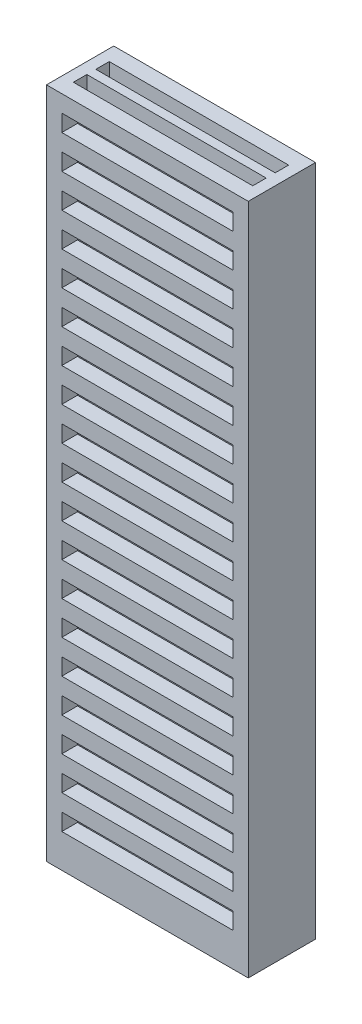
from build123d import *

# Parameters (mm, degrees)
SKETCH1_W                = 9
SKETCH1_H                = 3
BOSS_EXTRUDE1_DEPTH      = 15
CUT_EXTRUDE1_START       = -31
SKETCH2_W                = 8
SKETCH2_H                = 0.6
CUT_EXTRUDE1_DEPTH       = 32
SKETCH3_W                = 7.634272068
SKETCH3_H                = 0.75
CUT_EXTRUDE2_DEPTH       = 0.7
LPATTERN1_COUNT          = 19
LPATTERN1_PITCH          = 1.5
MIRROR2_COPY_1_SKETCH_W  = 7.634272068
MIRROR2_COPY_1_SKETCH_H  = 0.75
MIRROR2_COPY_1_DEPTH     = 0.7
MIRROR2_COPY_2_SKETCH_W  = 7.634272068
MIRROR2_COPY_2_SKETCH_H  = 0.75
MIRROR2_COPY_2_DEPTH     = 0.7
MIRROR2_COPY_3_SKETCH_W  = 7.634272068
MIRROR2_COPY_3_SKETCH_H  = 0.75
MIRROR2_COPY_3_DEPTH     = 0.7
MIRROR2_COPY_4_SKETCH_W  = 7.634272068
MIRROR2_COPY_4_SKETCH_H  = 0.75
MIRROR2_COPY_4_DEPTH     = 0.7
MIRROR2_COPY_5_SKETCH_W  = 7.634272068
MIRROR2_COPY_5_SKETCH_H  = 0.75
MIRROR2_COPY_5_DEPTH     = 0.7
MIRROR2_COPY_6_SKETCH_W  = 7.634272068
MIRROR2_COPY_6_SKETCH_H  = 0.75
MIRROR2_COPY_6_DEPTH     = 0.7
MIRROR2_COPY_7_SKETCH_W  = 7.634272068
MIRROR2_COPY_7_SKETCH_H  = 0.75
MIRROR2_COPY_7_DEPTH     = 0.7
MIRROR2_COPY_8_SKETCH_W  = 7.634272068
MIRROR2_COPY_8_SKETCH_H  = 0.75
MIRROR2_COPY_8_DEPTH     = 0.7
MIRROR2_COPY_9_SKETCH_W  = 7.634272068
MIRROR2_COPY_9_SKETCH_H  = 0.75
MIRROR2_COPY_9_DEPTH     = 0.7
MIRROR2_COPY_10_SKETCH_W = 7.634272068
MIRROR2_COPY_10_SKETCH_H = 0.75
MIRROR2_COPY_10_DEPTH    = 0.7
MIRROR2_COPY_11_SKETCH_W = 7.634272068
MIRROR2_COPY_11_SKETCH_H = 0.75
MIRROR2_COPY_11_DEPTH    = 0.7
MIRROR2_COPY_12_SKETCH_W = 7.634272068
MIRROR2_COPY_12_SKETCH_H = 0.75
MIRROR2_COPY_12_DEPTH    = 0.7
MIRROR2_COPY_13_SKETCH_W = 7.634272068
MIRROR2_COPY_13_SKETCH_H = 0.75
MIRROR2_COPY_13_DEPTH    = 0.7
MIRROR2_COPY_14_SKETCH_W = 7.634272068
MIRROR2_COPY_14_SKETCH_H = 0.75
MIRROR2_COPY_14_DEPTH    = 0.7
MIRROR2_COPY_15_SKETCH_W = 7.634272068
MIRROR2_COPY_15_SKETCH_H = 0.75
MIRROR2_COPY_15_DEPTH    = 0.7
MIRROR2_COPY_16_SKETCH_W = 7.634272068
MIRROR2_COPY_16_SKETCH_H = 0.75
MIRROR2_COPY_16_DEPTH    = 0.7
MIRROR2_COPY_17_SKETCH_W = 7.634272068
MIRROR2_COPY_17_SKETCH_H = 0.75
MIRROR2_COPY_17_DEPTH    = 0.7
MIRROR2_COPY_18_SKETCH_W = 7.634272068
MIRROR2_COPY_18_SKETCH_H = 0.75
MIRROR2_COPY_18_DEPTH    = 0.7


with BuildPart() as part:
    # Sketch1 → Boss-Extrude1 (new body, symmetric)
    with BuildSketch(Plane(origin=(0, 0, 0), x_dir=(1, 0, 0), z_dir=(0, 1, 0))):
        Rectangle(SKETCH1_W, SKETCH1_H)
    extrude(amount=BOSS_EXTRUDE1_DEPTH, both=True)

    # Sketch2 → Cut-Extrude1 (cut)
    with BuildSketch(Plane(origin=(0, 15, 0), x_dir=(1, 0, 0), z_dir=(0, 1, 0)).offset(CUT_EXTRUDE1_START)):
        with Locations((0, 0.5)):
            Rectangle(SKETCH2_W, SKETCH2_H)
    cut_extrude1 = extrude(amount=CUT_EXTRUDE1_DEPTH, mode=Mode.SUBTRACT)

    # Mirror1: Cut-Extrude1 across plane
    add(cut_extrude1.mirror(Plane.XY), mode=Mode.SUBTRACT)

    # Sketch3 → Cut-Extrude2 (cut)
    with BuildSketch(Plane.XY.offset(1.5)):
        with Locations((0, 13.875)):
            Rectangle(SKETCH3_W, SKETCH3_H)
    cut_extrude2 = extrude(amount=-CUT_EXTRUDE2_DEPTH, mode=Mode.SUBTRACT)

    # LPattern1: Cut-Extrude2 ×19
    with Locations(*[(0, -i * LPATTERN1_PITCH, 0) for i in range(1, LPATTERN1_COUNT)]):
        add(cut_extrude2, mode=Mode.SUBTRACT)

    # Mirror2: Cut-Extrude2 across plane
    add(cut_extrude2.mirror(Plane.XY), mode=Mode.SUBTRACT)

    # Mirror2 copy 1 sketch → Mirror2 copy 1 (cut)
    with BuildSketch(Plane(origin=(0, -1.5, -1.5), x_dir=(1, 0, 0), z_dir=(0, 0, -1))):
        with Locations((0, -13.875)):
            Rectangle(MIRROR2_COPY_1_SKETCH_W, MIRROR2_COPY_1_SKETCH_H)
    extrude(amount=-MIRROR2_COPY_1_DEPTH, mode=Mode.SUBTRACT)

    # Mirror2 copy 2 sketch → Mirror2 copy 2 (cut)
    with BuildSketch(Plane(origin=(0, -3, -1.5), x_dir=(1, 0, 0), z_dir=(0, 0, -1))):
        with Locations((0, -13.875)):
            Rectangle(MIRROR2_COPY_2_SKETCH_W, MIRROR2_COPY_2_SKETCH_H)
    extrude(amount=-MIRROR2_COPY_2_DEPTH, mode=Mode.SUBTRACT)

    # Mirror2 copy 3 sketch → Mirror2 copy 3 (cut)
    with BuildSketch(Plane(origin=(0, -4.5, -1.5), x_dir=(1, 0, 0), z_dir=(0, 0, -1))):
        with Locations((0, -13.875)):
            Rectangle(MIRROR2_COPY_3_SKETCH_W, MIRROR2_COPY_3_SKETCH_H)
    extrude(amount=-MIRROR2_COPY_3_DEPTH, mode=Mode.SUBTRACT)

    # Mirror2 copy 4 sketch → Mirror2 copy 4 (cut)
    with BuildSketch(Plane(origin=(0, -6, -1.5), x_dir=(1, 0, 0), z_dir=(0, 0, -1))):
        with Locations((0, -13.875)):
            Rectangle(MIRROR2_COPY_4_SKETCH_W, MIRROR2_COPY_4_SKETCH_H)
    extrude(amount=-MIRROR2_COPY_4_DEPTH, mode=Mode.SUBTRACT)

    # Mirror2 copy 5 sketch → Mirror2 copy 5 (cut)
    with BuildSketch(Plane(origin=(0, -7.5, -1.5), x_dir=(1, 0, 0), z_dir=(0, 0, -1))):
        with Locations((0, -13.875)):
            Rectangle(MIRROR2_COPY_5_SKETCH_W, MIRROR2_COPY_5_SKETCH_H)
    extrude(amount=-MIRROR2_COPY_5_DEPTH, mode=Mode.SUBTRACT)

    # Mirror2 copy 6 sketch → Mirror2 copy 6 (cut)
    with BuildSketch(Plane(origin=(0, -9, -1.5), x_dir=(1, 0, 0), z_dir=(0, 0, -1))):
        with Locations((0, -13.875)):
            Rectangle(MIRROR2_COPY_6_SKETCH_W, MIRROR2_COPY_6_SKETCH_H)
    extrude(amount=-MIRROR2_COPY_6_DEPTH, mode=Mode.SUBTRACT)

    # Mirror2 copy 7 sketch → Mirror2 copy 7 (cut)
    with BuildSketch(Plane(origin=(0, -10.5, -1.5), x_dir=(1, 0, 0), z_dir=(0, 0, -1))):
        with Locations((0, -13.875)):
            Rectangle(MIRROR2_COPY_7_SKETCH_W, MIRROR2_COPY_7_SKETCH_H)
    extrude(amount=-MIRROR2_COPY_7_DEPTH, mode=Mode.SUBTRACT)

    # Mirror2 copy 8 sketch → Mirror2 copy 8 (cut)
    with BuildSketch(Plane(origin=(0, -12, -1.5), x_dir=(1, 0, 0), z_dir=(0, 0, -1))):
        with Locations((0, -13.875)):
            Rectangle(MIRROR2_COPY_8_SKETCH_W, MIRROR2_COPY_8_SKETCH_H)
    extrude(amount=-MIRROR2_COPY_8_DEPTH, mode=Mode.SUBTRACT)

    # Mirror2 copy 9 sketch → Mirror2 copy 9 (cut)
    with BuildSketch(Plane(origin=(0, -13.5, -1.5), x_dir=(1, 0, 0), z_dir=(0, 0, -1))):
        with Locations((0, -13.875)):
            Rectangle(MIRROR2_COPY_9_SKETCH_W, MIRROR2_COPY_9_SKETCH_H)
    extrude(amount=-MIRROR2_COPY_9_DEPTH, mode=Mode.SUBTRACT)

    # Mirror2 copy 10 sketch → Mirror2 copy 10 (cut)
    with BuildSketch(Plane(origin=(0, -15, -1.5), x_dir=(1, 0, 0), z_dir=(0, 0, -1))):
        with Locations((0, -13.875)):
            Rectangle(MIRROR2_COPY_10_SKETCH_W, MIRROR2_COPY_10_SKETCH_H)
    extrude(amount=-MIRROR2_COPY_10_DEPTH, mode=Mode.SUBTRACT)

    # Mirror2 copy 11 sketch → Mirror2 copy 11 (cut)
    with BuildSketch(Plane(origin=(0, -16.5, -1.5), x_dir=(1, 0, 0), z_dir=(0, 0, -1))):
        with Locations((0, -13.875)):
            Rectangle(MIRROR2_COPY_11_SKETCH_W, MIRROR2_COPY_11_SKETCH_H)
    extrude(amount=-MIRROR2_COPY_11_DEPTH, mode=Mode.SUBTRACT)

    # Mirror2 copy 12 sketch → Mirror2 copy 12 (cut)
    with BuildSketch(Plane(origin=(0, -18, -1.5), x_dir=(1, 0, 0), z_dir=(0, 0, -1))):
        with Locations((0, -13.875)):
            Rectangle(MIRROR2_COPY_12_SKETCH_W, MIRROR2_COPY_12_SKETCH_H)
    extrude(amount=-MIRROR2_COPY_12_DEPTH, mode=Mode.SUBTRACT)

    # Mirror2 copy 13 sketch → Mirror2 copy 13 (cut)
    with BuildSketch(Plane(origin=(0, -19.5, -1.5), x_dir=(1, 0, 0), z_dir=(0, 0, -1))):
        with Locations((0, -13.875)):
            Rectangle(MIRROR2_COPY_13_SKETCH_W, MIRROR2_COPY_13_SKETCH_H)
    extrude(amount=-MIRROR2_COPY_13_DEPTH, mode=Mode.SUBTRACT)

    # Mirror2 copy 14 sketch → Mirror2 copy 14 (cut)
    with BuildSketch(Plane(origin=(0, -21, -1.5), x_dir=(1, 0, 0), z_dir=(0, 0, -1))):
        with Locations((0, -13.875)):
            Rectangle(MIRROR2_COPY_14_SKETCH_W, MIRROR2_COPY_14_SKETCH_H)
    extrude(amount=-MIRROR2_COPY_14_DEPTH, mode=Mode.SUBTRACT)

    # Mirror2 copy 15 sketch → Mirror2 copy 15 (cut)
    with BuildSketch(Plane(origin=(0, -22.5, -1.5), x_dir=(1, 0, 0), z_dir=(0, 0, -1))):
        with Locations((0, -13.875)):
            Rectangle(MIRROR2_COPY_15_SKETCH_W, MIRROR2_COPY_15_SKETCH_H)
    extrude(amount=-MIRROR2_COPY_15_DEPTH, mode=Mode.SUBTRACT)

    # Mirror2 copy 16 sketch → Mirror2 copy 16 (cut)
    with BuildSketch(Plane(origin=(0, -24, -1.5), x_dir=(1, 0, 0), z_dir=(0, 0, -1))):
        with Locations((0, -13.875)):
            Rectangle(MIRROR2_COPY_16_SKETCH_W, MIRROR2_COPY_16_SKETCH_H)
    extrude(amount=-MIRROR2_COPY_16_DEPTH, mode=Mode.SUBTRACT)

    # Mirror2 copy 17 sketch → Mirror2 copy 17 (cut)
    with BuildSketch(Plane(origin=(0, -25.5, -1.5), x_dir=(1, 0, 0), z_dir=(0, 0, -1))):
        with Locations((0, -13.875)):
            Rectangle(MIRROR2_COPY_17_SKETCH_W, MIRROR2_COPY_17_SKETCH_H)
    extrude(amount=-MIRROR2_COPY_17_DEPTH, mode=Mode.SUBTRACT)

    # Mirror2 copy 18 sketch → Mirror2 copy 18 (cut)
    with BuildSketch(Plane(origin=(0, -27, -1.5), x_dir=(1, 0, 0), z_dir=(0, 0, -1))):
        with Locations((0, -13.875)):
            Rectangle(MIRROR2_COPY_18_SKETCH_W, MIRROR2_COPY_18_SKETCH_H)
    extrude(amount=-MIRROR2_COPY_18_DEPTH, mode=Mode.SUBTRACT)


solid = part.part
